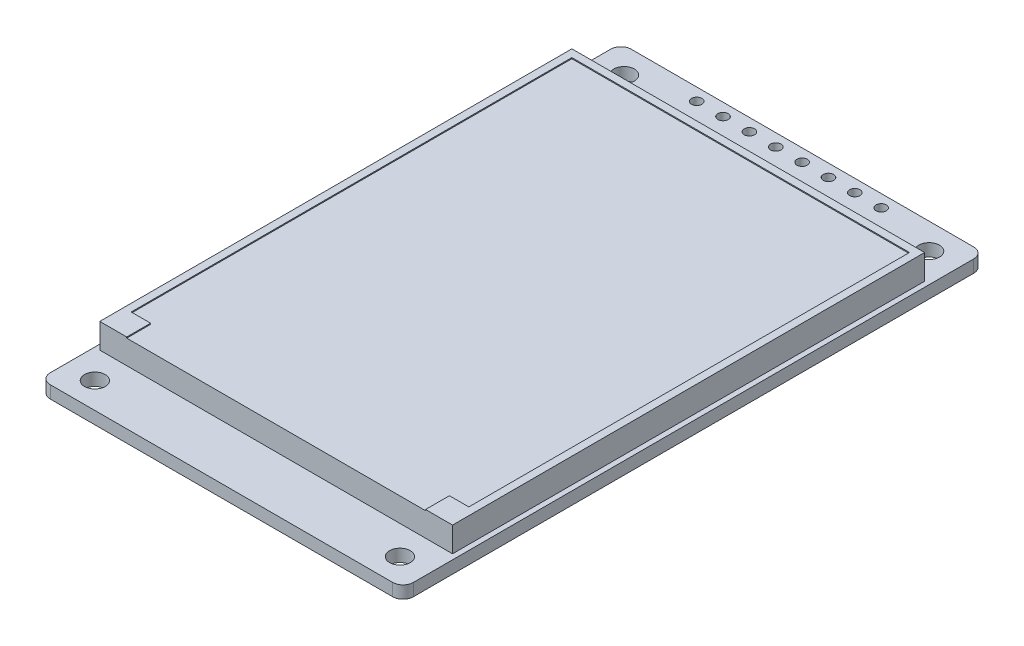
from build123d import *

# Parameters (mm, degrees)
SKETCH1_W           = 35
SKETCH1_H           = 56
SKETCH1_R           = 1
SKETCH1_R_2         = 0.5
BOSS_EXTRUDE1_DEPTH = 1.2
FILLET1_R           = 1
SKETCH2_W           = 34
SKETCH2_H           = 45.5
BOSS_EXTRUDE2_DEPTH = 2.4
CUT_EXTRUDE1_DEPTH  = 0.1


with BuildPart() as part:
    # Sketch1 → Boss-Extrude1 (new body)
    with BuildSketch(Plane(origin=(0, 0, 0), x_dir=(1, 0, 0), z_dir=(0, 1, 0))):
        Rectangle(SKETCH1_W, SKETCH1_H)
        with Locations((-14.7, 25.5)):
            Circle(SKETCH1_R, mode=Mode.SUBTRACT)
        with Locations((14.7, 25.5)):
            Circle(SKETCH1_R, mode=Mode.SUBTRACT)
        with Locations((-14.7, -25.5)):
            Circle(SKETCH1_R, mode=Mode.SUBTRACT)
        with Locations((14.7, -25.5)):
            Circle(SKETCH1_R, mode=Mode.SUBTRACT)
        with Locations((-9, 26.8)):
            Circle(SKETCH1_R_2, mode=Mode.SUBTRACT)
        with Locations((-6.46, 26.8)):
            Circle(SKETCH1_R_2, mode=Mode.SUBTRACT)
        with Locations((-3.92, 26.8)):
            Circle(SKETCH1_R_2, mode=Mode.SUBTRACT)
        with Locations((-1.38, 26.8)):
            Circle(SKETCH1_R_2, mode=Mode.SUBTRACT)
        with Locations((1.16, 26.8)):
            Circle(SKETCH1_R_2, mode=Mode.SUBTRACT)
        with Locations((3.7, 26.8)):
            Circle(SKETCH1_R_2, mode=Mode.SUBTRACT)
        with Locations((6.24, 26.8)):
            Circle(SKETCH1_R_2, mode=Mode.SUBTRACT)
        with Locations((8.78, 26.8)):
            Circle(SKETCH1_R_2, mode=Mode.SUBTRACT)
    extrude(amount=BOSS_EXTRUDE1_DEPTH)

    # Fillet1
    fillet1_edges = [part.edges().sort_by_distance(p)[0] for p in [
        (17.5, 0.6, 28),
        (-17.5, 0.6, 28),
        (-17.5, 0.6, -28),
        (17.5, 0.6, -28),
    ]]
    fillet(fillet1_edges, radius=FILLET1_R)

    # Sketch2 → Boss-Extrude2 (add)
    with BuildSketch(Plane(origin=(0, 1.2, 0), x_dir=(1, 0, 0), z_dir=(0, 1, 0))):
        with Locations((0, 0.02)):
            Rectangle(SKETCH2_W, SKETCH2_H)
    extrude(amount=BOSS_EXTRUDE2_DEPTH)

    # Sketch3 → Cut-Extrude1 (cut)
    with BuildSketch(Plane(origin=(0, 3.6, 0), x_dir=(1, 0, 0), z_dir=(0, 1, 0))):
        Polygon((-16.27, 22.04), (16.27, 22.04), (16.27, -20.43), (14.4, -20.43), (14.4, -22.73), (-14.4, -22.73), (-14.4, -20.43), (-16.27, -20.43), align=None)
    extrude(amount=-CUT_EXTRUDE1_DEPTH, mode=Mode.SUBTRACT)


solid = part.part
